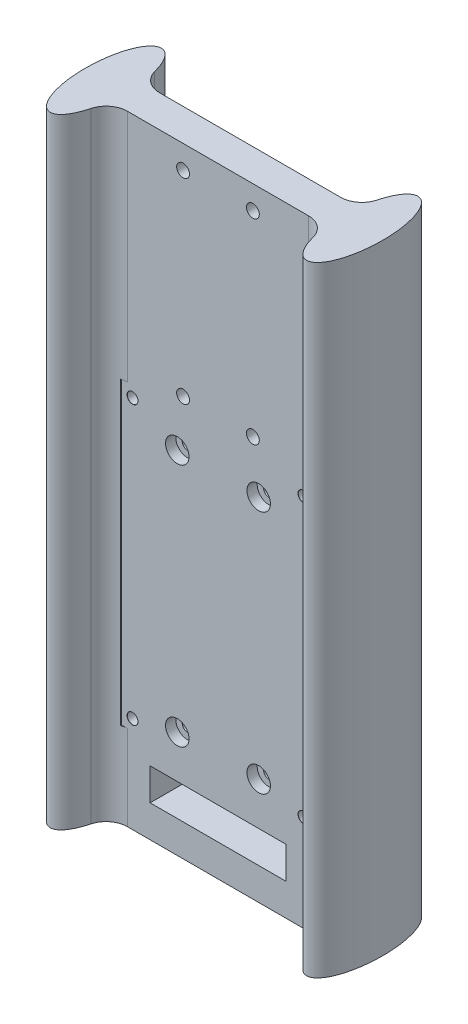
from build123d import *

# Parameters (mm, degrees)
BOSS_EXTRUDE1_DEPTH               = 145
FILLET1_R                         = 5
SKETCH3_W                         = 31.75
SKETCH3_H                         = 7.5
CUT_EXTRUDE2_DEPTH                = 10.2500001
CUT_EXTRUDE2_DEPTH_BACK           = 17.7500001
TAP_DRILL_FOR_M3X0_5_TAP1_D       = 2.5
SKETCH5_W                         = 45.2
SKETCH5_H                         = 70.2
SKETCH5_W_2                       = 35
SKETCH5_H_2                       = 60
CUT_EXTRUDE3_DEPTH                = 10
SKETCH6_R                         = 2.75
CUT_EXTRUDE4_DEPTH                = 2.4
TAP_DRILL_FOR_M3_TAP1_D           = 2.5
TAP_DRILL_FOR_M3_TAP1_CSINK_D     = 2.55
TAP_DRILL_FOR_M3_TAP1_CSINK_ANGLE = 90
SKETCH9_R                         = 1.5
CUT_EXTRUDE5_DEPTH                = 17.7500001


with BuildPart() as part:
    # Sketch1 → Boss-Extrude1 (new body)
    with BuildSketch(Plane(origin=(0, 0, 0), x_dir=(1, 0, 0), z_dir=(0, 1, 0))):
        with BuildLine():
            add(Edge.make_bspline(
                [(25.356166305, 3.75), (24.934680795, 0), (25.356166305, -3.75)],
                knots=[1.278176641, 1.278176641, 1.278176641, 1.863416012, 1.863416012, 1.863416012], degree=2, weights=[1, 0.957491483, 1]))
            Line((25.356166305, 3.75), (-25.356166305, 3.75))
            add(Edge.make_bspline(
                [(-25.356166305, -3.75), (-24.934680795, 0), (-25.356166305, 3.75)],
                knots=[1.278176641, 1.278176641, 1.278176641, 1.863416012, 1.863416012, 1.863416012], degree=2, weights=[1, 0.957491483, 1]))
            Line((-25.356166305, -3.75), (25.356166305, -3.75))
        make_face()
        with BuildLine():
            add(Edge.make_bspline(
                [(-25.356166305, -3.75), (-24.934680795, 0), (-25.356166305, 3.75)],
                knots=[1.278176641, 1.278176641, 1.278176641, 1.863416012, 1.863416012, 1.863416012], degree=2, weights=[1, 0.957491483, 1]))
            Line((-25.356166305, 3.75), (-30, 3.75))
            Line((-30, 3.75), (-30, -3.75))
            Line((-30, -3.75), (-25.356166305, -3.75))
        make_face()
        with BuildLine():
            Line((-30, 3.75), (-25.356166305, 3.75))
            add(Edge.make_bspline(
                [(-25.356166305, 3.75), (-28.138876861, 28.508062419), (-33.892803395, 7.75403121), (-39.646729928, -13), (-30, -13)],
                knots=[1.863416012, 1.863416012, 1.863416012, 4.07330066, 4.07330066, 6.283185307, 6.283185307, 6.283185307], degree=2, weights=[1, 0.449185964, 1, 0.449185964, 1]))
            add(Edge.make_bspline(
                [(-30, -13), (-26.395830565, -13), (-25.356166305, -3.75)],
                knots=[0, 0, 0, 1.278176641, 1.278176641, 1.278176641], degree=2, weights=[1, 0.802639875, 1]))
            Line((-25.356166305, -3.75), (-30, -3.75))
            Line((-30, -3.75), (-30, 3.75))
        make_face()
        with BuildLine():
            add(Edge.make_bspline(
                [(-25.356166305, -3.75), (-24.934680795, 0), (-25.356166305, 3.75)],
                knots=[1.278176641, 1.278176641, 1.278176641, 1.863416012, 1.863416012, 1.863416012], degree=2, weights=[1, 0.957491483, 1]))
            Line((-25.356166305, 3.75), (-30, 3.75))
            Line((-30, 3.75), (-30, -3.75))
            Line((-30, -3.75), (-25.356166305, -3.75))
        make_face()
        with BuildLine():
            Line((-30, 3.75), (-25.356166305, 3.75))
            add(Edge.make_bspline(
                [(-25.356166305, 3.75), (-28.138876861, 28.508062419), (-33.892803395, 7.75403121), (-39.646729928, -13), (-30, -13)],
                knots=[1.863416012, 1.863416012, 1.863416012, 4.07330066, 4.07330066, 6.283185307, 6.283185307, 6.283185307], degree=2, weights=[1, 0.449185964, 1, 0.449185964, 1]))
            add(Edge.make_bspline(
                [(-30, -13), (-26.395830565, -13), (-25.356166305, -3.75)],
                knots=[0, 0, 0, 1.278176641, 1.278176641, 1.278176641], degree=2, weights=[1, 0.802639875, 1]))
            Line((-25.356166305, -3.75), (-30, -3.75))
            Line((-30, -3.75), (-30, 3.75))
        make_face()
        with BuildLine():
            Line((30, -3.75), (30, 3.75))
            Line((30, 3.75), (25.356166305, 3.75))
            add(Edge.make_bspline(
                [(25.356166305, 3.75), (24.934680795, 0), (25.356166305, -3.75)],
                knots=[1.278176641, 1.278176641, 1.278176641, 1.863416012, 1.863416012, 1.863416012], degree=2, weights=[1, 0.957491483, 1]))
            Line((25.356166305, -3.75), (30, -3.75))
        make_face()
        with BuildLine():
            Line((25.356166305, 3.75), (30, 3.75))
            Line((30, 3.75), (30, -3.75))
            Line((30, -3.75), (25.356166305, -3.75))
            add(Edge.make_bspline(
                [(25.356166305, -3.75), (28.138876861, -28.508062419), (33.892803395, -7.75403121), (39.646729928, 13), (30, 13)],
                knots=[1.863416012, 1.863416012, 1.863416012, 4.07330066, 4.07330066, 6.283185307, 6.283185307, 6.283185307], degree=2, weights=[1, 0.449185964, 1, 0.449185964, 1]))
            add(Edge.make_bspline(
                [(30, 13), (26.395830565, 13), (25.356166305, 3.75)],
                knots=[0, 0, 0, 1.278176641, 1.278176641, 1.278176641], degree=2, weights=[1, 0.802639875, 1]))
        make_face()
        with BuildLine():
            Line((30, -3.75), (30, 3.75))
            Line((30, 3.75), (25.356166305, 3.75))
            add(Edge.make_bspline(
                [(25.356166305, 3.75), (24.934680795, 0), (25.356166305, -3.75)],
                knots=[1.278176641, 1.278176641, 1.278176641, 1.863416012, 1.863416012, 1.863416012], degree=2, weights=[1, 0.957491483, 1]))
            Line((25.356166305, -3.75), (30, -3.75))
        make_face()
        with BuildLine():
            Line((25.356166305, 3.75), (30, 3.75))
            Line((30, 3.75), (30, -3.75))
            Line((30, -3.75), (25.356166305, -3.75))
            add(Edge.make_bspline(
                [(25.356166305, -3.75), (28.138876861, -28.508062419), (33.892803395, -7.75403121), (39.646729928, 13), (30, 13)],
                knots=[1.863416012, 1.863416012, 1.863416012, 4.07330066, 4.07330066, 6.283185307, 6.283185307, 6.283185307], degree=2, weights=[1, 0.449185964, 1, 0.449185964, 1]))
            add(Edge.make_bspline(
                [(30, 13), (26.395830565, 13), (25.356166305, 3.75)],
                knots=[0, 0, 0, 1.278176641, 1.278176641, 1.278176641], degree=2, weights=[1, 0.802639875, 1]))
        make_face()
    extrude(amount=BOSS_EXTRUDE1_DEPTH)

    # Fillet1
    fillet1_edges = [part.edges().sort_by_distance(p)[0] for p in [
        (-25.356166305, 72.5, -3.75),
        (25.356166305, 72.5, -3.75),
        (25.356166305, 72.5, 3.75),
        (-25.356166305, 72.5, 3.75),
    ]]
    fillet(fillet1_edges, radius=FILLET1_R)

    # Sketch3 → Cut-Extrude2 (cut, two sides)
    with BuildSketch(Plane(origin=(0, 0, -3.75), x_dir=(-1, 0, 0), z_dir=(0, 0, -1))) as cut_extrude2_sk:
        with Locations((0, 11.25)):
            Rectangle(SKETCH3_W, SKETCH3_H)
    extrude(amount=CUT_EXTRUDE2_DEPTH, mode=Mode.SUBTRACT)
    extrude(cut_extrude2_sk.sketch, amount=-CUT_EXTRUDE2_DEPTH_BACK, mode=Mode.SUBTRACT)

    # Tap Drill for M3x0.5 Tap1 (through all)
    with Locations(Plane(origin=(9.525, 82.15, -3.75), x_dir=(-1, 0, 0), z_dir=(0, 0, -1))):
        with Locations((0, 0), (19.05, 0), (19.05, -57.15), (0, -57.15)):
            Hole(TAP_DRILL_FOR_M3X0_5_TAP1_D / 2)

    # Sketch5 → Cut-Extrude3 (cut)
    with BuildSketch(Plane.XY.offset(3.75)):
        with Locations((0, 55)):
            Rectangle(SKETCH5_W, SKETCH5_H)
        with Locations((0, 55)):
            Rectangle(SKETCH5_W_2, SKETCH5_H_2, mode=Mode.SUBTRACT)
    extrude(amount=CUT_EXTRUDE3_DEPTH, mode=Mode.SUBTRACT)

    # Sketch6 → Cut-Extrude4 (cut)
    with BuildSketch(Plane.XY.offset(3.75)):
        with Locations((9.525, 82.15)):
            Circle(SKETCH6_R)
        with Locations((-9.525, 82.15)):
            Circle(SKETCH6_R)
        with Locations((9.525, 25)):
            Circle(SKETCH6_R)
        with Locations((-9.525, 25)):
            Circle(SKETCH6_R)
    extrude(amount=-CUT_EXTRUDE4_DEPTH, mode=Mode.SUBTRACT)

    # Tap Drill for M3 Tap1 (through all)
    with Locations(Plane.XY.offset(3.75)):
        with Locations((-20, 87.5), (20, 87.5), (20, 22.5), (-20, 22.5)):
            CounterSinkHole(TAP_DRILL_FOR_M3_TAP1_D / 2, TAP_DRILL_FOR_M3_TAP1_CSINK_D / 2, counter_sink_angle=TAP_DRILL_FOR_M3_TAP1_CSINK_ANGLE)

    # Sketch9 → Cut-Extrude5 (cut, through all)
    with BuildSketch(Plane(origin=(0, 0, -3.75), x_dir=(-1, 0, 0), z_dir=(0, 0, -1))):
        with Locations((-8.168, 139.5)):
            Circle(SKETCH9_R)
        with Locations((8.168, 139.5)):
            Circle(SKETCH9_R)
        with Locations((8.168, 93.7)):
            Circle(SKETCH9_R)
        with Locations((-8.168, 93.7)):
            Circle(SKETCH9_R)
    extrude(amount=-CUT_EXTRUDE5_DEPTH, mode=Mode.SUBTRACT)


solid = part.part
